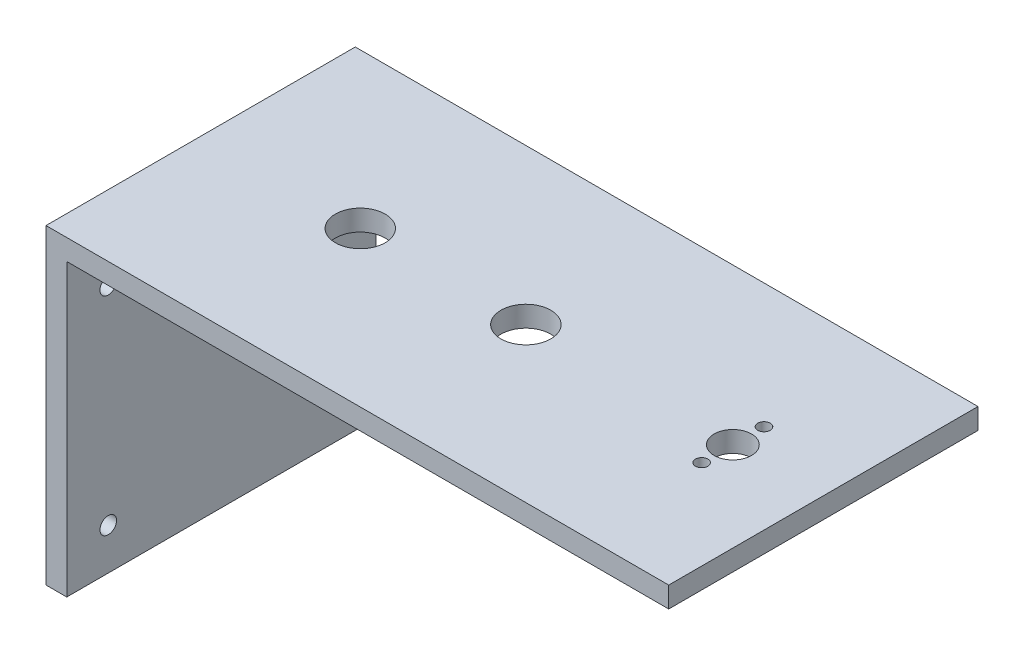
from build123d import *

# Parameters (mm, degrees)
CROQUIS1_W              = 150
CROQUIS1_H              = 74.5
SALIENTE_EXTRUIR1_DEPTH = 5
CROQUIS2_W              = 5
CROQUIS2_H              = 74.5
SALIENTE_EXTRUIR2_DEPTH = 70
CROQUIS3_R              = 2
CORTAR_EXTRUIR1_DEPTH   = 70
CROQUIS4_R              = 6
CROQUIS4_R_2            = 4.5
CROQUIS4_R_3            = 1.5
CORTAR_EXTRUIR2_DEPTH   = 70


with BuildPart() as part:
    # Croquis1 → Saliente-Extruir1 (new body)
    with BuildSketch(Plane(origin=(0, 0, 0), x_dir=(1, 0, 0), z_dir=(0, 1, 0))):
        Rectangle(CROQUIS1_W, CROQUIS1_H)
    extrude(amount=SALIENTE_EXTRUIR1_DEPTH)

    # Croquis2 → Saliente-Extruir2 (add)
    with BuildSketch(Plane.XZ):
        with Locations((-72.5, 0)):
            Rectangle(CROQUIS2_W, CROQUIS2_H)
    extrude(amount=SALIENTE_EXTRUIR2_DEPTH)

    # Croquis3 → Cortar-Extruir1 (cut)
    with BuildSketch(Plane(origin=(-70, 0, 0), x_dir=(0, 0, -1), z_dir=(1, 0, 0))):
        with Locations((-27.25, -10)):
            Circle(CROQUIS3_R)
        with Locations((27.25, -10)):
            Circle(CROQUIS3_R)
        with Locations((27.25, -60)):
            Circle(CROQUIS3_R)
        with Locations((-27.25, -60)):
            Circle(CROQUIS3_R)
    extrude(amount=-CORTAR_EXTRUIR1_DEPTH, mode=Mode.SUBTRACT)

    # Croquis4 → Cortar-Extruir2 (cut)
    with BuildSketch(Plane(origin=(0, 5, 0), x_dir=(1, 0, 0), z_dir=(0, 1, 0))):
        with Locations((-36.55, 0)):
            Circle(CROQUIS4_R)
        with Locations((53.45, -0.25)):
            Circle(CROQUIS4_R_2)
        with Locations((53.45, 7.25)):
            Circle(CROQUIS4_R_3)
        with Locations((53.429166747, -7.749971065)):
            Circle(CROQUIS4_R_3)
        with Locations((3.44984568, -0.111110682)):
            Circle(CROQUIS4_R)
    extrude(amount=-CORTAR_EXTRUIR2_DEPTH, mode=Mode.SUBTRACT)


solid = part.part
